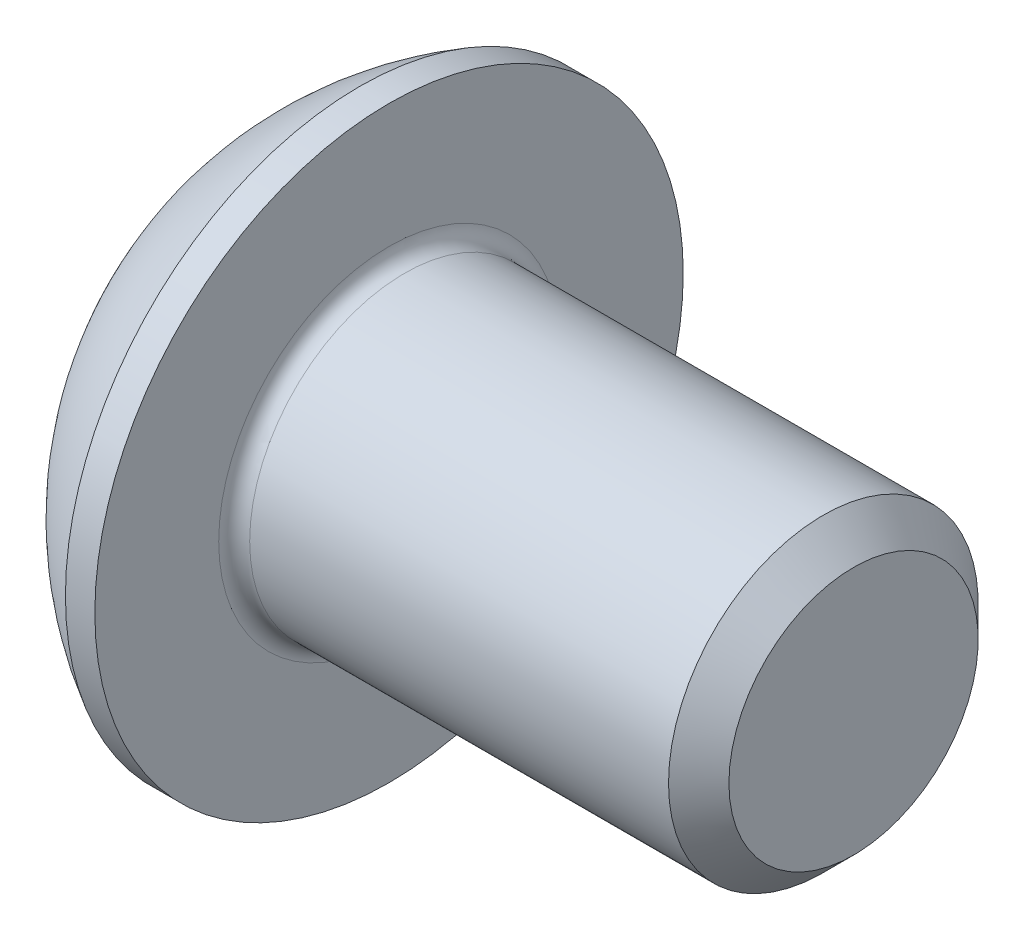
from build123d import *

# Parameters (mm, degrees)
FILLET1_R   = 0.2
HEX_2_DEPTH = 1.3


with BuildPart() as part:
    # BodySke → BaseBody (revolve)
    with BuildSketch(Plane.XY):
        with BuildLine():
            Line((8.2, 0), (8.2, 1.61))
            Line((8.2, 1.61), (7.81, 2))
            Line((7.81, 2), (2.2, 2))
            Line((2.2, 2), (2.2, 3.8))
            Line((2.2, 3.8), (1.82, 3.8))
            ThreePointArc((1.82, 3.8), (0.762013659, 2.991755338), (0, 1.9))
            Line((0, 1.9), (0, 0))
            Line((0, 0), (8.2, 0))
        make_face()
    revolve(axis=Axis((0, 0, 0), (1, 0, 0)))

    # Fillet1
    fillet1_edges = [part.edges().sort_by_distance(p)[0] for p in [
        (2.2, -2, 0),
    ]]
    fillet(fillet1_edges, radius=FILLET1_R)

    # Sketch2 → PreBroach (revolve, cut)
    with BuildSketch(Plane.XY):
        Polygon((0, 1.25), (1.3, 1.25), (2.021687836, 0), (0, 0), align=None)
    revolve(axis=Axis((0, 0, 0), (1, 0, 0)), mode=Mode.SUBTRACT)

    # Sketch3 → Hex 2 (cut)
    with BuildSketch(Plane(origin=(0, 0, 0), x_dir=(0, 0, -1), z_dir=(1, 0, 0))):
        Polygon((-1.25, -0.721687836), (-1.25, 0.721687836), (0, 1.443375673), (1.25, 0.721687836), (1.25, -0.721687836), (0, -1.443375673), align=None)
    extrude(amount=HEX_2_DEPTH, mode=Mode.SUBTRACT)


solid = part.part
